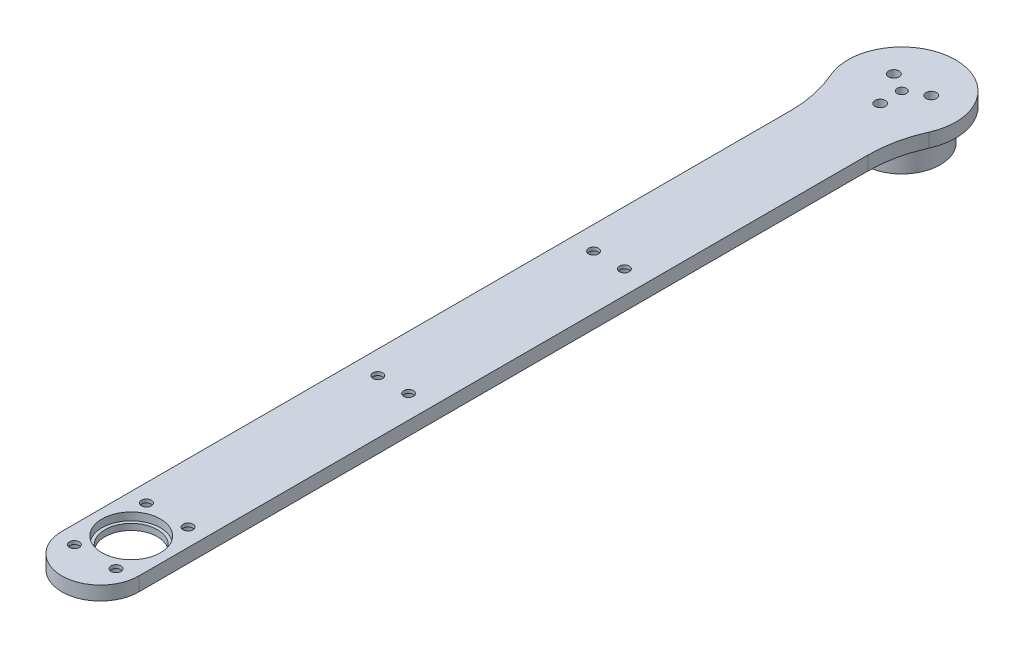
from build123d import *

# Parameters (mm, degrees)
EXTRUDE_1_DEPTH              = 9
SKETCH_3_R                   = 13.5
EXTRUDE_2_DEPTH              = 2
EXTRUDE_START                = 3
SKETCH_4_R                   = 13.5
EXTRUDE_3_DEPTH              = 3
SKETCH_5_R                   = 9.5
CUT_EXTRUDE_2_DEPTH          = 274.324898244
HOLE_WIZARD_M3_4_D           = 3.4
HOLE_WIZARD_M3_4_CBORE_D     = 6.5
HOLE_WIZARD_M3_4_CBORE_DEPTH = 3.4
PATTERN_CIRCULAR_1_COUNT     = 3
EXTRUDE_START_2              = 7
SKETCH_11_R                  = 12.5
SKETCH_11_R_2                = 3.25
EXTRUDE_4_DEPTH              = 7
SKETCH_13_R                  = 11
CUT_EXTRUDE_3_DEPTH          = 3
FILLET_1_R                   = 40
SKETCH_26_W                  = 65.136073631
SKETCH_26_H                  = 16.815092821
CUT_EXTRUDE_5_DEPTH          = 1111
EXTRUDE_START_3              = -2
SKETCH_28_R                  = 9.5
SKETCH_28_R_2                = 8.5
EXTRUDE_5_DEPTH              = 2
HOLE_WIZARD_M3_2_D           = 3.2
HOLE_WIZARD_M3_2_CBORE_D     = 6.5
HOLE_WIZARD_M3_2_CBORE_DEPTH = 3.4
PATTERN_LINEAR_1_COUNT       = 3
PATTERN_LINEAR_1_PITCH       = 70
PATTERN_LINEAR_1_COUNT_DIR2  = 2
PATTERN_LINEAR_1_PITCH_DIR2  = 10
HOLE_WIZARD_M3_3_D           = 3.2
HOLE_WIZARD_M3_3_CBORE_D     = 6.5
HOLE_WIZARD_M3_3_CBORE_DEPTH = 3.4
PATTERN_CIRCULAR_2_COUNT     = 6
SKETCH_39_R                  = 3.25
EXTRUDE_6_DEPTH              = 4.5
F_3_0MM_1_D                  = 3
F_3_0MM_1_DEPTH              = 5
F_3_0MM_1_TIP                = 0.901290929


with BuildPart() as part:
    # 스케치1 → 보스-돌출1 (new body)
    with BuildSketch(Plane(origin=(0, 0, 0), x_dir=(1, 0, 0), z_dir=(0, 1, 0))):
        with BuildLine():
            Line((-12.5, -260), (-12.5, -12.247448714))
            ThreePointArc((-12.5, -12.247448714), (0, 17.5), (12.5, -12.247448714))
            Line((12.5, -12.247448714), (12.5, -260))
            ThreePointArc((12.5, -260), (0, -272.5), (-12.5, -260))
        make_face()
    extrude(amount=EXTRUDE_1_DEPTH)

    # 스케치3 → 보스-돌출2 (add)
    with BuildSketch(Plane(origin=(0, 9, 0), x_dir=(1, 0, 0), z_dir=(0, 1, 0))):
        Circle(SKETCH_3_R)
    extrude(amount=EXTRUDE_2_DEPTH)

    # 스케치4 → 보스-돌출3 (add)
    with BuildSketch(Plane.XZ.offset(EXTRUDE_START)):
        Circle(SKETCH_4_R)
    extrude(amount=-EXTRUDE_3_DEPTH)

    # 스케치5 → 컷-돌출2 (cut, through all)
    with BuildSketch(Plane(origin=(0, 9, 0), x_dir=(1, 0, 0), z_dir=(0, 1, 0))):
        with Locations((0, -250)):
            Circle(SKETCH_5_R)
    extrude(amount=-CUT_EXTRUDE_2_DEPTH, mode=Mode.SUBTRACT)

    # M3 육각 소켓 머리 캡 나사용 카운터보어4 (through all)
    with Locations(Plane(origin=(0, -3, 0), x_dir=(-1, 0, 0), z_dir=(0, -1, 0))):
        with Locations((0, -7)):
            hole_wizard_m3_4 = CounterBoreHole(HOLE_WIZARD_M3_4_D / 2, HOLE_WIZARD_M3_4_CBORE_D / 2, HOLE_WIZARD_M3_4_CBORE_DEPTH)

    # 원형 패턴1: M3 육각 소켓 머리 캡 나사용 카운터보어4 ×3 about axis
    pattern_circular_1_axis = Axis((0, 9, 0), (0, -1, 0))
    for i in range(1, PATTERN_CIRCULAR_1_COUNT):
        add(hole_wizard_m3_4.rotate(pattern_circular_1_axis, i * 360 / PATTERN_CIRCULAR_1_COUNT), mode=Mode.SUBTRACT)

    # 스케치11 → 보스-돌출4 (add)
    with BuildSketch(Plane.XZ.offset(3).offset(EXTRUDE_START_2)):
        Circle(SKETCH_11_R)
        with Locations((-6.062177826, -3.5)):
            Circle(SKETCH_11_R_2, mode=Mode.SUBTRACT)
        with Locations((6.062177826, -3.5)):
            Circle(SKETCH_11_R_2, mode=Mode.SUBTRACT)
        with Locations((0, 7)):
            Circle(SKETCH_11_R_2, mode=Mode.SUBTRACT)
    extrude(amount=-EXTRUDE_4_DEPTH)

    # 스케치13 → 컷-돌출3 (cut)
    with BuildSketch(Plane(origin=(0, 11, 0), x_dir=(1, 0, 0), z_dir=(0, 1, 0))):
        Circle(SKETCH_13_R)
    extrude(amount=-CUT_EXTRUDE_3_DEPTH, mode=Mode.SUBTRACT)

    # 필렛1
    fillet_1_edges = [part.edges().sort_by_distance(p)[0] for p in [
        (12.5, 4.5, 12.247448714),
        (-12.5, 4.5, 12.247448714),
    ]]
    fillet(fillet_1_edges, radius=FILLET_1_R)

    # 스케치26 → 컷-돌출5 (cut, symmetric)
    with BuildSketch(Plane.XY):
        with Locations((0.11753139, 12.907546411)):
            Rectangle(SKETCH_26_W, SKETCH_26_H)
    extrude(amount=CUT_EXTRUDE_5_DEPTH, both=True, mode=Mode.SUBTRACT)

    # 스케치28 → 보스-돌출5 (add)
    with BuildSketch(Plane.XZ.offset(EXTRUDE_START_3)):
        with Locations((0, 250)):
            Circle(SKETCH_28_R)
        with Locations((0, 250)):
            Circle(SKETCH_28_R_2, mode=Mode.SUBTRACT)
    extrude(amount=EXTRUDE_5_DEPTH)

    # M3 육각 소켓 머리 캡 나사용 카운터보어2 (through all)
    with Locations(Plane(origin=(0, 0, 0), x_dir=(-1, 0, 0), z_dir=(0, -1, 0))):
        with Locations((5, -25)):
            hole_wizard_m3_2 = CounterBoreHole(HOLE_WIZARD_M3_2_D / 2, HOLE_WIZARD_M3_2_CBORE_D / 2, HOLE_WIZARD_M3_2_CBORE_DEPTH)

    # 선형 패턴1: Hole Wizard M3 _ _ _ _ _ _2 3 × 2
    with Locations(*[(j * PATTERN_LINEAR_1_PITCH_DIR2, 0, i * PATTERN_LINEAR_1_PITCH) for i in range(PATTERN_LINEAR_1_COUNT) for j in range(PATTERN_LINEAR_1_COUNT_DIR2) if (i, j) != (0, 0)]):
        add(hole_wizard_m3_2, mode=Mode.SUBTRACT)

    # M3 육각 소켓 머리 캡 나사용 카운터보어3 (through all)
    with Locations(Plane(origin=(0, 0, 0), x_dir=(-1, 0, 0), z_dir=(0, -1, 0))):
        with Locations((6.75, -261.691342951)):
            hole_wizard_m3_3 = CounterBoreHole(HOLE_WIZARD_M3_3_D / 2, HOLE_WIZARD_M3_3_CBORE_D / 2, HOLE_WIZARD_M3_3_CBORE_DEPTH)

    # 원형 패턴2: M3 육각 소켓 머리 캡 나사용 카운터보어3 ×6 about axis, 2 skipped
    pattern_circular_2_axis = Axis((0, 2, 250), (0, -1, 0))
    add([hole_wizard_m3_3.rotate(pattern_circular_2_axis, i * 360 / PATTERN_CIRCULAR_2_COUNT) for i in range(1, PATTERN_CIRCULAR_2_COUNT) if i not in (1, 4)], mode=Mode.SUBTRACT)

    # 스케치39 → 보스-돌출6 (add)
    with BuildSketch(Plane.XZ):
        with Locations((5, 25)):
            Circle(SKETCH_39_R)
        with Locations((-5, 25)):
            Circle(SKETCH_39_R)
    extrude(amount=-EXTRUDE_6_DEPTH)

    # Ø3.0mm 맞춤핀 구멍1
    with Locations(Plane(origin=(0, 4.5, 0), x_dir=(1, 0, 0), z_dir=(0, 1, 0))):
        with Locations((0, 0)):
            Hole(F_3_0MM_1_D / 2, depth=F_3_0MM_1_DEPTH)
            with Locations((0, 0, -(F_3_0MM_1_DEPTH + F_3_0MM_1_TIP / 2))):  # 118° drill point
                Cone(0, F_3_0MM_1_D / 2, F_3_0MM_1_TIP, mode=Mode.SUBTRACT)


solid = part.part
